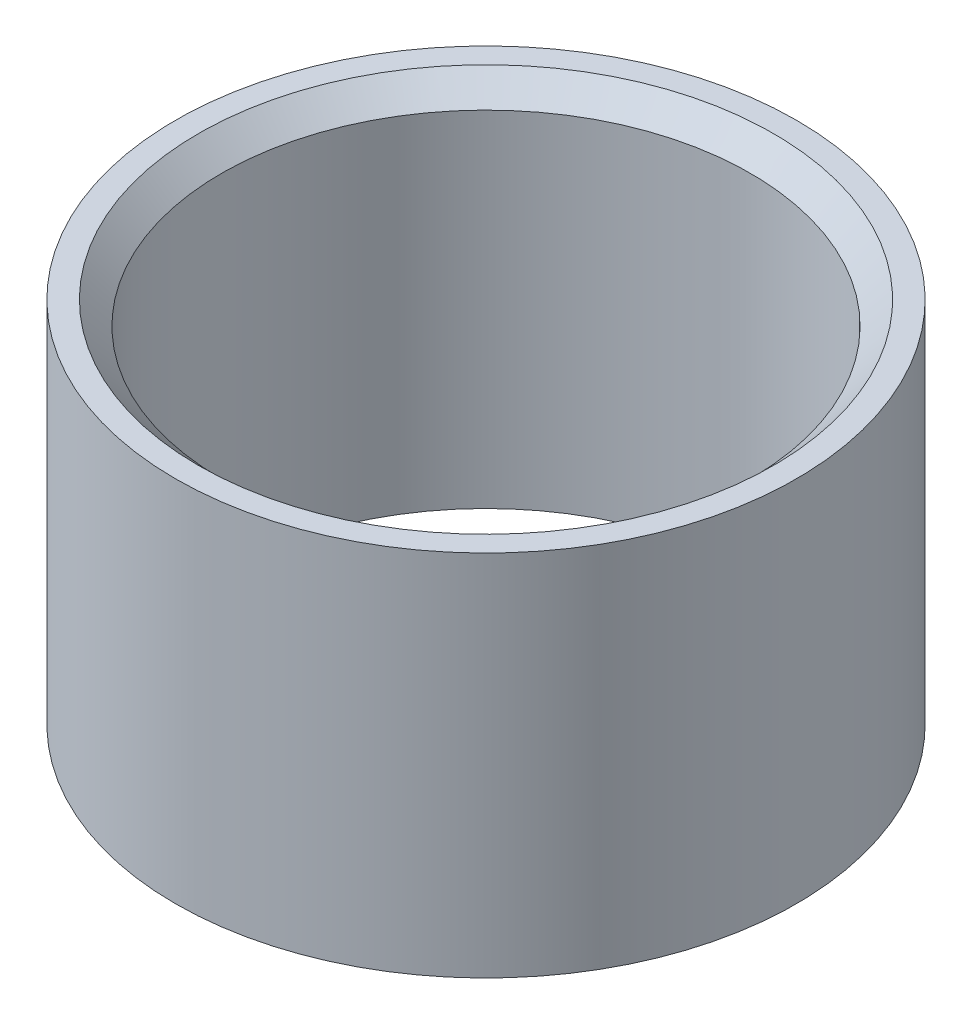
from build123d import *

# Parameters (mm, degrees)
SKETCH1_R           = 1.35
BOSS_EXTRUDE1_DEPTH = 1.6
SKETCH2_R           = 1.15
CUT_EXTRUDE1_DEPTH  = 2.6
CHAMFER1_SIZE       = 0.1


with BuildPart() as part:
    # Sketch1 → Boss-Extrude1 (new body)
    with BuildSketch(Plane(origin=(0, 0, 0), x_dir=(1, 0, 0), z_dir=(0, 1, 0))):
        Circle(SKETCH1_R)
    extrude(amount=BOSS_EXTRUDE1_DEPTH)

    # Sketch2 → Cut-Extrude1 (cut, through all)
    with BuildSketch(Plane(origin=(0, 1.6, 0), x_dir=(1, 0, 0), z_dir=(0, 1, 0))):
        Circle(SKETCH2_R)
    extrude(amount=-CUT_EXTRUDE1_DEPTH, mode=Mode.SUBTRACT)

    # Chamfer1
    chamfer1_edges = [part.edges().sort_by_distance(p)[0] for p in [
        (-1.15, 1.6, 0),
    ]]
    chamfer(chamfer1_edges, length=CHAMFER1_SIZE)


solid = part.part
